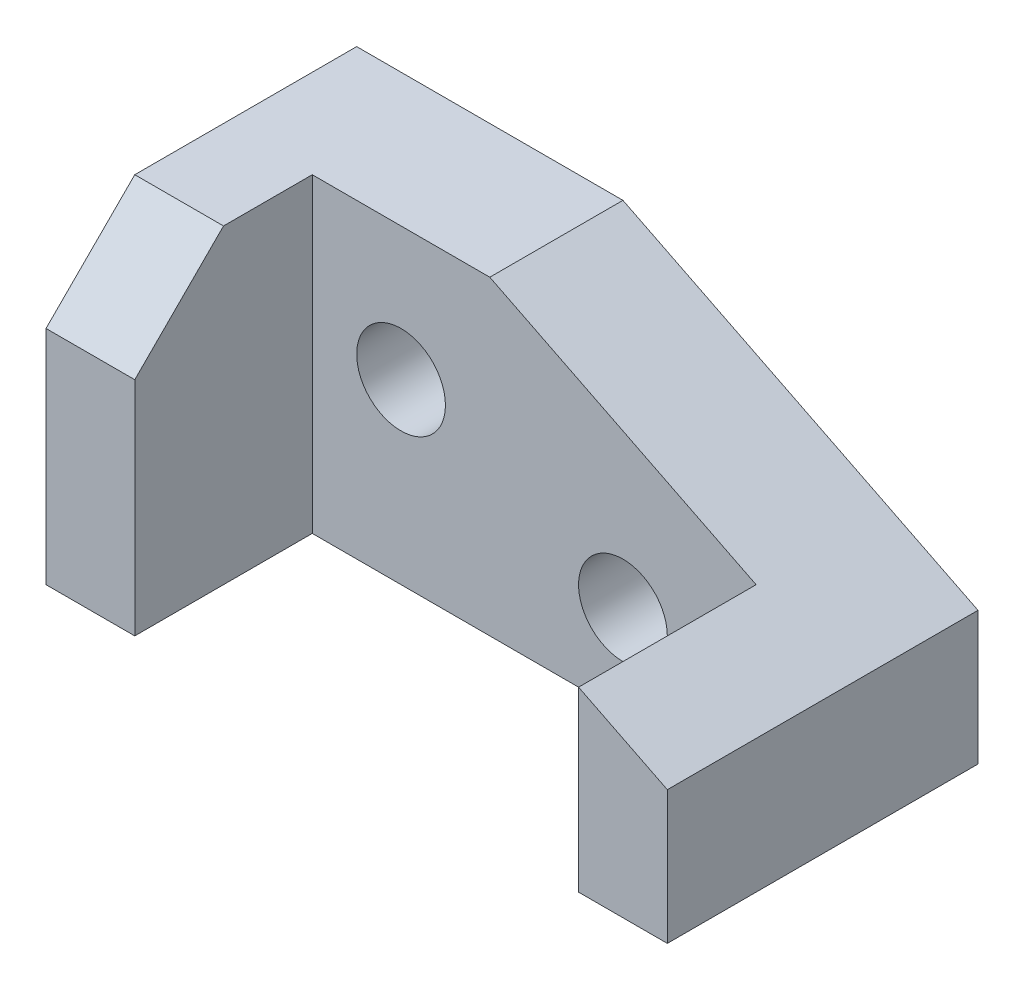
from build123d import *

# Parameters (mm, degrees)
SKETCH1_W           = 70
SKETCH1_H           = 35
BOSS_EXTRUDE1_DEPTH = 35
SKETCH2_W           = 50
SKETCH2_H           = 20
CUT_EXTRUDE1_DEPTH  = 36
CUT_EXTRUDE2_DEPTH  = 36
CUT_EXTRUDE3_DEPTH  = 35
SKETCH5_R           = 5
CUT_EXTRUDE4_DEPTH  = 35
SKETCH6_R           = 5
CUT_EXTRUDE5_DEPTH  = 35


with BuildPart() as part:
    # Sketch1 → Boss-Extrude1 (new body)
    with BuildSketch(Plane(origin=(0, 0, 0), x_dir=(1, 0, 0), z_dir=(0, 1, 0))):
        with Locations((35, 17.5)):
            Rectangle(SKETCH1_W, SKETCH1_H)
    extrude(amount=BOSS_EXTRUDE1_DEPTH)

    # Sketch2 → Cut-Extrude1 (cut, through all)
    with BuildSketch(Plane(origin=(0, 35, 0), x_dir=(1, 0, 0), z_dir=(0, 1, 0))):
        with Locations((35, 10)):
            Rectangle(SKETCH2_W, SKETCH2_H)
    extrude(amount=-CUT_EXTRUDE1_DEPTH, mode=Mode.SUBTRACT)

    # Sketch3 → Cut-Extrude2 (cut, through all)
    with BuildSketch(Plane(origin=(0, 0, -35), x_dir=(-1, 0, 0), z_dir=(0, 0, -1))):
        Polygon((-70, 35), (-70, 15), (-30, 35), align=None)
    extrude(amount=-CUT_EXTRUDE2_DEPTH, mode=Mode.SUBTRACT)

    # Sketch4 → Cut-Extrude3 (cut)
    with BuildSketch(Plane.ZY):
        Polygon((0, 35), (-10, 35), (0, 25), align=None)
    extrude(amount=-CUT_EXTRUDE3_DEPTH, mode=Mode.SUBTRACT)

    # Sketch5 → Cut-Extrude4 (cut)
    with BuildSketch(Plane.XY.offset(-20)):
        with Locations((20, 20)):
            Circle(SKETCH5_R)
    extrude(amount=-CUT_EXTRUDE4_DEPTH, mode=Mode.SUBTRACT)

    # Sketch6 → Cut-Extrude5 (cut)
    with BuildSketch(Plane.XY.offset(-20)):
        with Locations((45, 10)):
            Circle(SKETCH6_R)
    extrude(amount=-CUT_EXTRUDE5_DEPTH, mode=Mode.SUBTRACT)


solid = part.part
